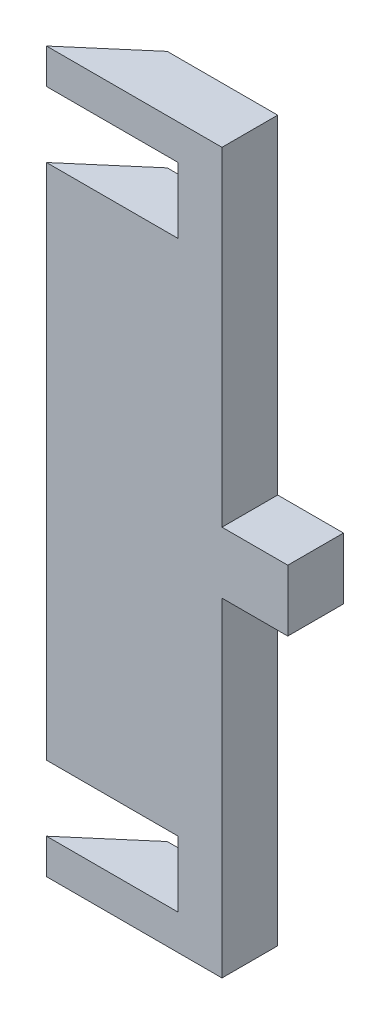
from build123d import *

# Parameters (mm, degrees)
SALIENTE_EXTRUIR1_DEPTH    = 170
CROQUIS2_W                 = 8
CROQUIS2_H                 = 27
CORTAR_EXTRUIR1_DEPTH      = 1
CORTAR_EXTRUIR1_DEPTH_BACK = 16
CROQUIS3_W                 = 38.06511858
CROQUIS3_H                 = 175.826127046
CORTAR_EXTRUIR2_DEPTH      = 1
CORTAR_EXTRUIR2_DEPTH_BACK = 16
CROQUIS4_W                 = 35.532251822
CROQUIS4_H                 = 7.536766594
CORTAR_EXTRUIR3_DEPTH      = 1
CORTAR_EXTRUIR3_DEPTH_BACK = 171
CROQUIS5_W                 = 14.817344245
CROQUIS5_H                 = 15
CROQUIS5_W_2               = 15.182655755
CROQUIS5_W_3               = 6
CROQUIS5_H_2               = 75
CROQUIS5_H_3               = 6
CORTAR_EXTRUIR4_DEPTH      = 1
CORTAR_EXTRUIR4_DEPTH_BACK = 13.7
CROQUIS6_W                 = 9
CROQUIS6_H                 = 14
SALIENTE_EXTRUIR2_DEPTH    = 12.7


with BuildPart() as part:
    # Croquis1 → Saliente-Extruir1 (new body)
    with BuildSketch(Plane(origin=(0, 0, 0), x_dir=(1, 0, 0), z_dir=(0, 1, 0))):
        Polygon((0, 0), (17.50080029, 15), (60, 15), (60, 0), align=None)
    extrude(amount=SALIENTE_EXTRUIR1_DEPTH)

    # Croquis2 → Cortar-Extruir1 (cut, two sides)
    with BuildSketch(Plane(origin=(0, 0, -15), x_dir=(-1, 0, 0), z_dir=(0, 0, -1))) as cortar_extruir1_sk:
        with Locations((-56, 13.5)):
            Rectangle(CROQUIS2_W, CROQUIS2_H)
        with Locations((-56, 156.5)):
            Rectangle(CROQUIS2_W, CROQUIS2_H)
    extrude(amount=CORTAR_EXTRUIR1_DEPTH, mode=Mode.SUBTRACT)
    extrude(cortar_extruir1_sk.sketch, amount=-CORTAR_EXTRUIR1_DEPTH_BACK, mode=Mode.SUBTRACT)

    # Croquis3 → Cortar-Extruir2 (cut, two sides)
    with BuildSketch(Plane(origin=(0, 0, -15), x_dir=(-1, 0, 0), z_dir=(0, 0, -1))) as cortar_extruir2_sk:
        with Locations((-65.03255929, 82.086936477)):
            Rectangle(CROQUIS3_W, CROQUIS3_H)
    extrude(amount=CORTAR_EXTRUIR2_DEPTH, mode=Mode.SUBTRACT)
    extrude(cortar_extruir2_sk.sketch, amount=-CORTAR_EXTRUIR2_DEPTH_BACK, mode=Mode.SUBTRACT)

    # Croquis4 → Cortar-Extruir3 (cut, two sides)
    with BuildSketch(Plane.XZ) as cortar_extruir3_sk:
        with Locations((28.233874089, -16.468383297)):
            Rectangle(CROQUIS4_W, CROQUIS4_H)
    extrude(amount=CORTAR_EXTRUIR3_DEPTH, mode=Mode.SUBTRACT)
    extrude(cortar_extruir3_sk.sketch, amount=-CORTAR_EXTRUIR3_DEPTH_BACK, mode=Mode.SUBTRACT)

    # Croquis5 → Cortar-Extruir4 (cut, two sides)
    with BuildSketch(Plane(origin=(0, 0, -12.7), x_dir=(-1, 0, 0), z_dir=(0, 0, -1))) as cortar_extruir4_sk:
        with Locations((-7.408672123, 21.5)):
            Rectangle(CROQUIS5_W, CROQUIS5_H)
        with Locations((-22.408672123, 21.5)):
            Rectangle(CROQUIS5_W_2, CROQUIS5_H)
        with Locations((-43, 43.5)):
            Rectangle(CROQUIS5_W_3, CROQUIS5_H_2)
        Polygon((-40, 6), (-46, 6), (-46, 0), (-14.817344245, 0), (-14.817344245, 6), align=None)
        with Locations((-7.408672123, 3)):
            Rectangle(CROQUIS5_W, CROQUIS5_H_3)
        with Locations((-43, 132.5)):
            Rectangle(CROQUIS5_W_3, CROQUIS5_H_2)
        with Locations((-22.408672123, 154.5)):
            Rectangle(CROQUIS5_W_2, CROQUIS5_H)
        with Locations((-7.408672123, 154.5)):
            Rectangle(CROQUIS5_W, CROQUIS5_H)
    extrude(amount=CORTAR_EXTRUIR4_DEPTH, mode=Mode.SUBTRACT)
    extrude(cortar_extruir4_sk.sketch, amount=-CORTAR_EXTRUIR4_DEPTH_BACK, mode=Mode.SUBTRACT)

    # Croquis6 → Saliente-Extruir2 (add)
    with BuildSketch(Plane(origin=(0, 0, -12.7), x_dir=(-1, 0, 0), z_dir=(0, 0, -1))):
        with Locations((-50.5, 88)):
            Rectangle(CROQUIS6_W, CROQUIS6_H)
    extrude(amount=-SALIENTE_EXTRUIR2_DEPTH)


solid = part.part
